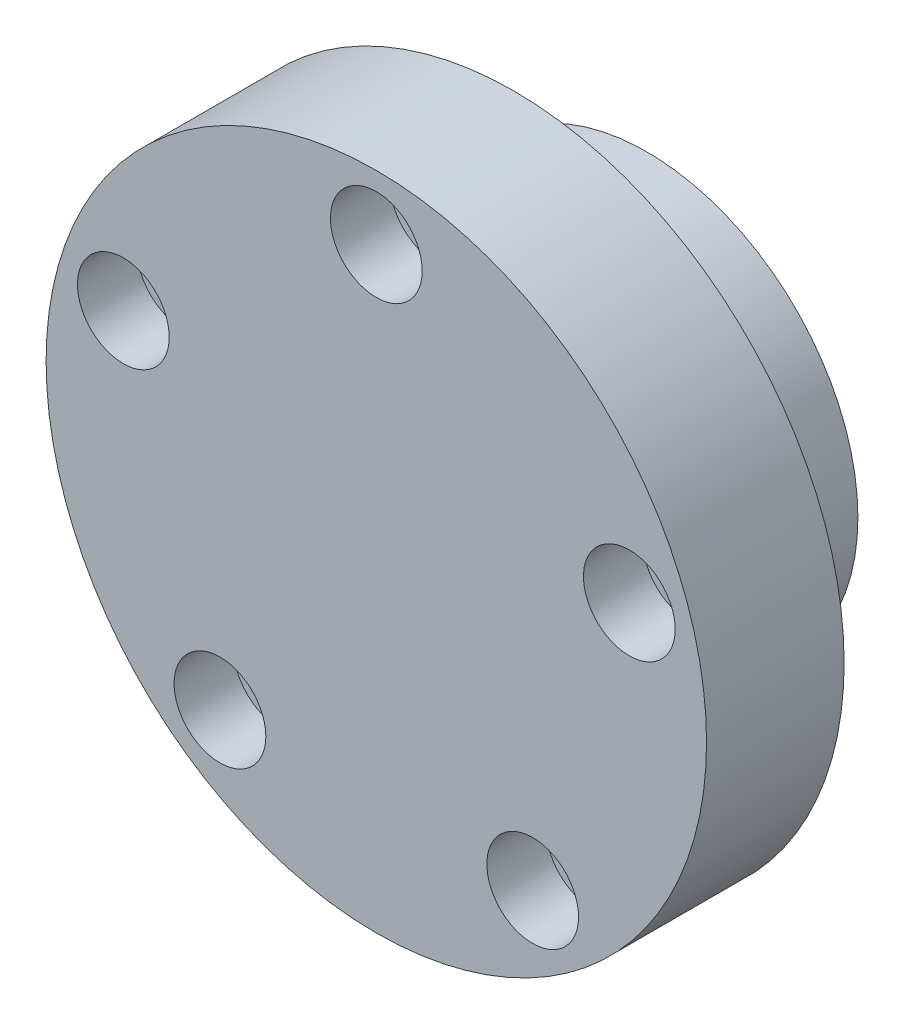
from build123d import *

# Parameters (mm, degrees)
SKETCH1_R           = 18
BOSS_EXTRUDE1_DEPTH = 7.5
SKETCH2_R           = 11.5
SKETCH2_R_2         = 4.5
BOSS_EXTRUDE2_DEPTH = 7.25
SKETCH3_R           = 1.524
CUT_EXTRUDE1_DEPTH  = 16.75
SKETCH4_R           = 2.5
CUT_EXTRUDE2_DEPTH  = 3.25


with BuildPart() as part:
    # Sketch1 → Boss-Extrude1 (new body)
    with BuildSketch(Plane.XY):
        Circle(SKETCH1_R)
    extrude(amount=BOSS_EXTRUDE1_DEPTH)

    # Sketch2 → Boss-Extrude2 (add)
    with BuildSketch(Plane(origin=(0, 0, 0), x_dir=(-1, 0, 0), z_dir=(0, 0, -1))):
        Circle(SKETCH2_R)
        Circle(SKETCH2_R_2, mode=Mode.SUBTRACT)
    extrude(amount=BOSS_EXTRUDE2_DEPTH)

    # Sketch3 → Cut-Extrude1 (cut)
    with BuildSketch(Plane.XY.offset(7.5)):
        with Locations((0, 14.5)):
            Circle(SKETCH3_R)
        with Locations((13.790319486, 4.480746418)):
            Circle(SKETCH3_R)
        with Locations((8.522886158, -11.730746418)):
            Circle(SKETCH3_R)
        with Locations((-8.522886158, -11.730746418)):
            Circle(SKETCH3_R)
        with Locations((-13.790319486, 4.480746418)):
            Circle(SKETCH3_R)
    extrude(amount=-CUT_EXTRUDE1_DEPTH, mode=Mode.SUBTRACT)

    # Sketch4 → Cut-Extrude2 (cut)
    with BuildSketch(Plane.XY.offset(7.5)):
        with Locations((0, 14.5)):
            Circle(SKETCH4_R)
        with Locations((13.790319486, 4.480746418)):
            Circle(SKETCH4_R)
        with Locations((8.522886158, -11.730746418)):
            Circle(SKETCH4_R)
        with Locations((-8.522886158, -11.730746418)):
            Circle(SKETCH4_R)
        with Locations((-13.790319486, 4.480746418)):
            Circle(SKETCH4_R)
    extrude(amount=-CUT_EXTRUDE2_DEPTH, mode=Mode.SUBTRACT)


solid = part.part
